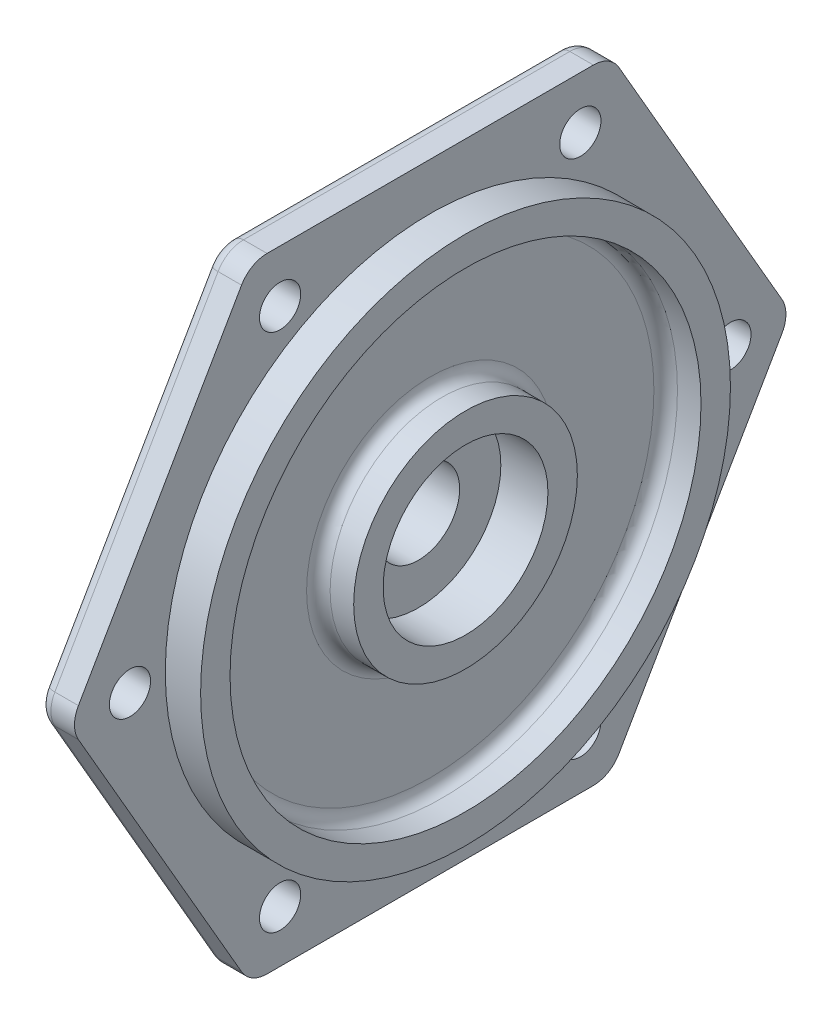
from build123d import *

# Parameters (mm, degrees)
SKETCH1_R               = 3.5
BOSS_EXTRUDE1_DEPTH     = 6
FILLET1_R               = 2
SKETCH2_R               = 45
SKETCH2_R_2             = 40
BOSS_EXTRUDE2_DEPTH     = 6
FILLET2_R               = 2
SKETCH3_R               = 19
SKETCH3_R_2             = 14
BOSS_EXTRUDE3_DEPTH     = 6
FILLET3_R               = 2
SKETCH4_R               = 14
CUT_EXTRUDE1_DEPTH      = 2
SKETCH6_R               = 23
BOSS_EXTRUDE4_DEPTH     = 4
SKETCH7_R               = 7
CUT_EXTRUDE2_DEPTH      = 9
CUT_EXTRUDE2_DEPTH_BACK = 9


with BuildPart() as part:
    # Sketch1 → Boss-Extrude1 (new body)
    with BuildSketch(Plane(origin=(0, 0, 0), x_dir=(0, 0, -1), z_dir=(1, 0, 0))):
        with BuildLine():
            Line((59.755752861, 2.5), (32.04293994, 50.5))
            ThreePointArc((32.04293994, 50.5), (30.212812921, 52.330127019), (27.712812921, 53))
            Line((27.712812921, 53), (-27.712812921, 53))
            ThreePointArc((-27.712812921, 53), (-30.212812921, 52.330127019), (-32.04293994, 50.5))
            Line((-32.04293994, 50.5), (-59.755752861, 2.5))
            ThreePointArc((-59.755752861, 2.5), (-60.425625842, 0), (-59.755752861, -2.5))
            Line((-59.755752861, -2.5), (-32.04293994, -50.5))
            ThreePointArc((-32.04293994, -50.5), (-30.212812921, -52.330127019), (-27.712812921, -53))
            Line((-27.712812921, -53), (27.712812921, -53))
            ThreePointArc((27.712812921, -53), (30.212812921, -52.330127019), (32.04293994, -50.5))
            Line((32.04293994, -50.5), (59.755752861, -2.5))
            ThreePointArc((59.755752861, -2.5), (60.425625842, 0), (59.755752861, 2.5))
        make_face()
        with Locations((-51, 0)):
            Circle(SKETCH1_R, mode=Mode.SUBTRACT)
        with Locations((-25.5, 44.167295593)):
            Circle(SKETCH1_R, mode=Mode.SUBTRACT)
        with Locations((25.5, 44.167295593)):
            Circle(SKETCH1_R, mode=Mode.SUBTRACT)
        with Locations((51, 0)):
            Circle(SKETCH1_R, mode=Mode.SUBTRACT)
        with Locations((25.5, -44.167295593)):
            Circle(SKETCH1_R, mode=Mode.SUBTRACT)
        with Locations((-25.5, -44.167295593)):
            Circle(SKETCH1_R, mode=Mode.SUBTRACT)
    extrude(amount=BOSS_EXTRUDE1_DEPTH)

    # Fillet1
    fillet1_edges = [part.edges().sort_by_distance(p)[0] for p in [
        (0, 26.5, -45.899346401),
        (0, 0, -60.425625842),
        (0, -26.5, -45.899346401),
        (0, -52.330127019, -30.212812921),
        (0, -53, 0),
        (0, -52.330127019, 30.212812921),
        (0, -26.5, 45.899346401),
        (0, 0, 60.425625842),
        (0, 26.5, 45.899346401),
        (0, 52.330127019, 30.212812921),
        (0, 53, 0),
        (0, 52.330127019, -30.212812921),
    ]]
    fillet(fillet1_edges, radius=FILLET1_R)

    # Sketch2 → Boss-Extrude2 (add)
    with BuildSketch(Plane(origin=(6, 0, 0), x_dir=(0, 0, -1), z_dir=(1, 0, 0))):
        Circle(SKETCH2_R)
        Circle(SKETCH2_R_2, mode=Mode.SUBTRACT)
    extrude(amount=BOSS_EXTRUDE2_DEPTH)

    # Fillet2
    fillet2_edges = [part.edges().sort_by_distance(p)[0] for p in [
        (6, 0, 40),
    ]]
    fillet(fillet2_edges, radius=FILLET2_R)

    # Sketch3 → Boss-Extrude3 (add)
    with BuildSketch(Plane(origin=(6, 0, 0), x_dir=(0, 0, -1), z_dir=(1, 0, 0))):
        Circle(SKETCH3_R)
        Circle(SKETCH3_R_2, mode=Mode.SUBTRACT)
    extrude(amount=BOSS_EXTRUDE3_DEPTH)

    # Fillet3
    fillet3_edges = [part.edges().sort_by_distance(p)[0] for p in [
        (6, 0, 19),
    ]]
    fillet(fillet3_edges, radius=FILLET3_R)

    # Sketch4 → Cut-Extrude1 (cut)
    with BuildSketch(Plane(origin=(6, 0, 0), x_dir=(0, 0, -1), z_dir=(1, 0, 0))):
        Circle(SKETCH4_R)
    extrude(amount=-CUT_EXTRUDE1_DEPTH, mode=Mode.SUBTRACT)

    # Sketch6 → Boss-Extrude4 (add)
    with BuildSketch(Plane.ZY):
        Circle(SKETCH6_R)
    extrude(amount=BOSS_EXTRUDE4_DEPTH)

    # Sketch7 → Cut-Extrude2 (cut, two sides)
    with BuildSketch(Plane(origin=(4, 0, 0), x_dir=(0, 0, -1), z_dir=(1, 0, 0))) as cut_extrude2_sk:
        Circle(SKETCH7_R)
    extrude(amount=CUT_EXTRUDE2_DEPTH, mode=Mode.SUBTRACT)
    extrude(cut_extrude2_sk.sketch, amount=-CUT_EXTRUDE2_DEPTH_BACK, mode=Mode.SUBTRACT)


solid = part.part
